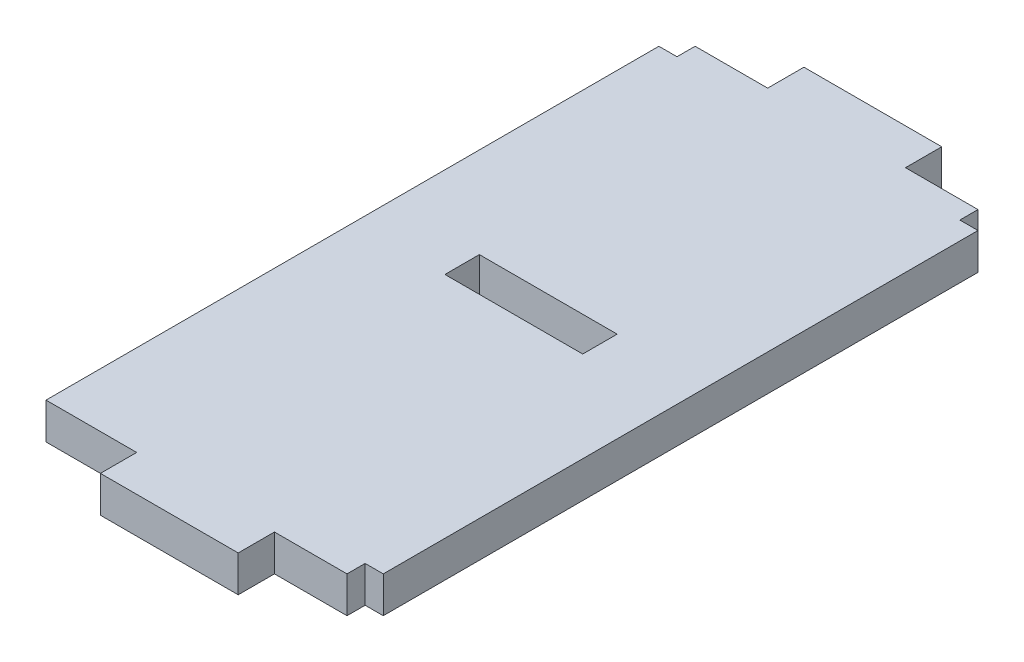
from build123d import *

# Parameters (mm, degrees)
SKETCH_1_W      = 7.6
SKETCH_1_H      = 1.9
EXTRUDE_1_DEPTH = 2


with BuildPart() as part:
    # 草图1 → 凸台-拉伸1 (new body)
    with BuildSketch(Plane(origin=(0, 0, 0), x_dir=(1, 0, 0), z_dir=(0, 1, 0))):
        Polygon((0, 33.8), (0, 0), (5, 0), (5, -2), (12.6, -2), (12.6, 0), (16.6, 0), (16.6, 1), (17.6, 1), (17.6, 33.8), (16.6, 33.8), (16.6, 34.8), (12.6, 34.8), (12.6, 36.8), (5, 36.8), (5, 34.8), (1, 34.8), (1, 33.8), align=None)
        with Locations((8.8, 17.95)):
            Rectangle(SKETCH_1_W, SKETCH_1_H, mode=Mode.SUBTRACT)
    extrude(amount=EXTRUDE_1_DEPTH)


solid = part.part
